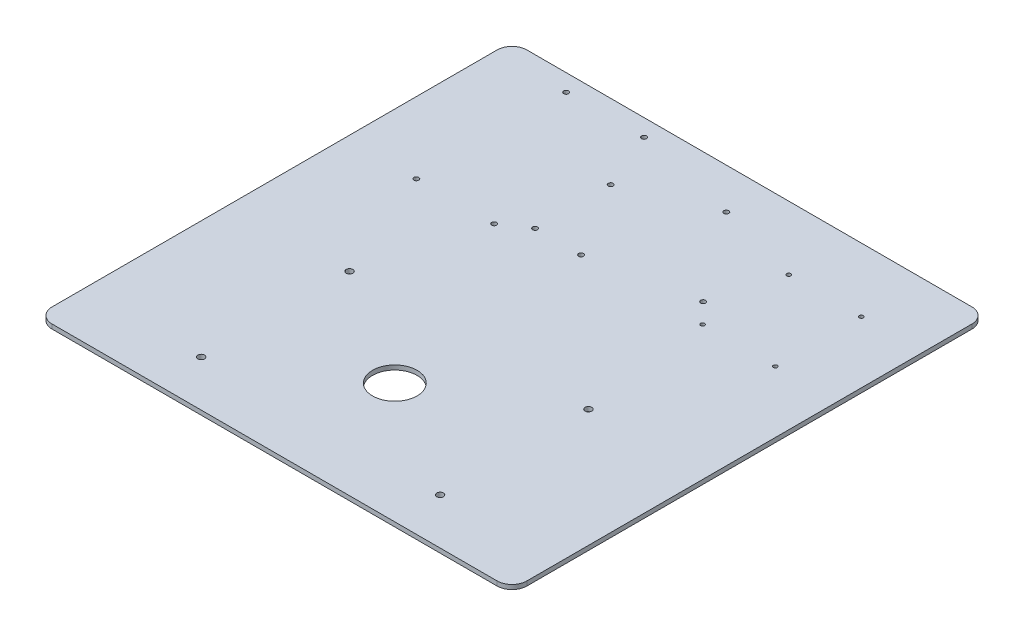
from build123d import *

# Parameters (mm, degrees)
SKETCH1_W           = 320
SKETCH1_H           = 320
SKETCH1_R           = 1.65
SKETCH1_R_2         = 1.35
SKETCH1_R_3         = 2.25
SKETCH1_R_4         = 15
BOSS_EXTRUDE1_DEPTH = 3
FILLET1_R           = 10


with BuildPart() as part:
    # Sketch1 → Boss-Extrude1 (new body)
    with BuildSketch(Plane(origin=(0, 0, 0), x_dir=(1, 0, 0), z_dir=(0, 1, 0))):
        with Locations((45.2, -56.43)):
            Rectangle(SKETCH1_W, SKETCH1_H)
        with Locations((101.6, 16)):
            Circle(SKETCH1_R, mode=Mode.SUBTRACT)
        with Locations((2.15, 2.15)):
            Circle(SKETCH1_R, mode=Mode.SUBTRACT)
        with Locations((33.15, 2.15)):
            Circle(SKETCH1_R, mode=Mode.SUBTRACT)
        with Locations((2.15, 53.15)):
            Circle(SKETCH1_R, mode=Mode.SUBTRACT)
        with Locations((57.1, 76.14)):
            Circle(SKETCH1_R, mode=Mode.SUBTRACT)
        with Locations((163.7, 2.57)):
            Circle(SKETCH1_R_2, mode=Mode.SUBTRACT)
        with Locations((114.7, 2.57)):
            Circle(SKETCH1_R_2, mode=Mode.SUBTRACT)
        with Locations((163.7, 60.57)):
            Circle(SKETCH1_R_2, mode=Mode.SUBTRACT)
        with Locations((114.7, 60.57)):
            Circle(SKETCH1_R_2, mode=Mode.SUBTRACT)
        with Locations((-14.3, -8.93)):
            Circle(SKETCH1_R, mode=Mode.SUBTRACT)
        with Locations((-66.8, -8.93)):
            Circle(SKETCH1_R, mode=Mode.SUBTRACT)
        with Locations((-14.3, 92.07)):
            Circle(SKETCH1_R, mode=Mode.SUBTRACT)
        with Locations((-66.8, 92.07)):
            Circle(SKETCH1_R, mode=Mode.SUBTRACT)
        with Locations((-35.3, -85.43)):
            Circle(SKETCH1_R_3, mode=Mode.SUBTRACT)
        with Locations((125.7, -85.43)):
            Circle(SKETCH1_R_3, mode=Mode.SUBTRACT)
        with Locations((125.7, -185.43)):
            Circle(SKETCH1_R_3, mode=Mode.SUBTRACT)
        with Locations((-35.3, -185.43)):
            Circle(SKETCH1_R_3, mode=Mode.SUBTRACT)
        with Locations((45.2, -135.43)):
            Circle(SKETCH1_R_4, mode=Mode.SUBTRACT)
    extrude(amount=BOSS_EXTRUDE1_DEPTH)

    # Fillet1
    fillet1_edges = [part.edges().sort_by_distance(p)[0] for p in [
        (205.2, 1.5, 216.43),
        (-114.8, 1.5, 216.43),
        (-114.8, 1.5, -103.57),
        (205.2, 1.5, -103.57),
    ]]
    fillet(fillet1_edges, radius=FILLET1_R)


solid = part.part
